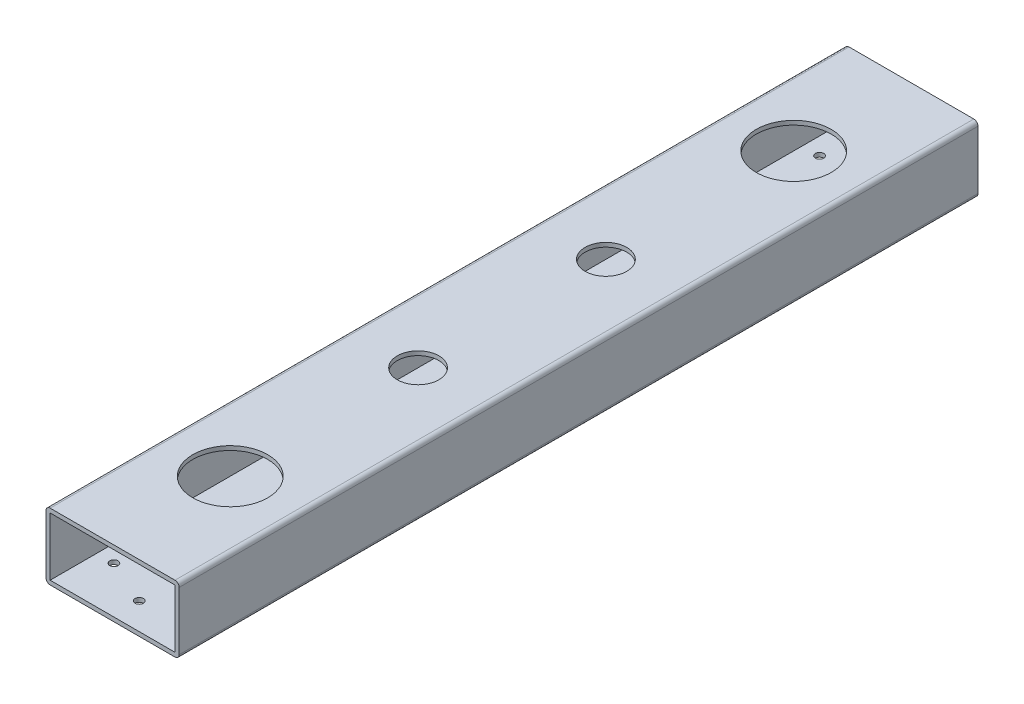
from build123d import *

# Parameters (mm, degrees)
SKETCH1_W                      = 47.625
SKETCH1_H                      = 22.225
BOSS_EXTRUDE1_DEPTH            = 304.8
CUT_EXTRUDE1_REACH             = 27.4
SKETCH2_R                      = 14.2875
CUT_EXTRUDE1_DIRECTION_2_DEPTH = 1
CUT_EXTRUDE2_REACH             = 27.4
SKETCH3_R                      = 12.7
CUT_EXTRUDE2_DIRECTION_2_DEPTH = 1
CUT_EXTRUDE5_REACH             = 27.4
SKETCH6_R                      = 3.3782
CUT_EXTRUDE5_DIRECTION_2_DEPTH = 1
CUT_EXTRUDE6_REACH             = 27.4
SKETCH7_R                      = 7.9375
CUT_EXTRUDE6_DIRECTION_2_DEPTH = 1
CUT_EXTRUDE7_REACH             = 27.4
SKETCH8_R                      = 1.5875
CUT_EXTRUDE7_DIRECTION_2_DEPTH = 1


with BuildPart() as part:
    # Sketch1 → Boss-Extrude1 (new body)
    with BuildSketch(Plane.XY):
        with BuildLine():
            Line((-23.8125, -12.7), (23.8125, -12.7))
            ThreePointArc((23.8125, -12.7), (24.935032015, -12.235032015), (25.4, -11.1125))
            Line((25.4, -11.1125), (25.4, 11.1125))
            ThreePointArc((25.4, 11.1125), (24.935032015, 12.235032015), (23.8125, 12.7))
            Line((23.8125, 12.7), (-23.8125, 12.7))
            ThreePointArc((-23.8125, 12.7), (-24.935032015, 12.235032015), (-25.4, 11.1125))
            Line((-25.4, 11.1125), (-25.4, -11.1125))
            ThreePointArc((-25.4, -11.1125), (-24.935032015, -12.235032015), (-23.8125, -12.7))
        make_face()
        Rectangle(SKETCH1_W, SKETCH1_H, mode=Mode.SUBTRACT)
    extrude(amount=BOSS_EXTRUDE1_DEPTH)

    # Sketch2 → Cut-Extrude1 (cut, up to next)
    with BuildSketch(Plane(origin=(0, 12.7, 0), x_dir=(1, 0, 0), z_dir=(0, 1, 0)), mode=Mode.PRIVATE) as cut_extrude1_sk1:
        with Locations((0, -259.9)):
            Circle(SKETCH2_R)
    cut_extrude1_tool1 = extrude(cut_extrude1_sk1.sketch, amount=-CUT_EXTRUDE1_REACH, mode=Mode.PRIVATE) & part.part
    add(cut_extrude1_tool1.solids().sort_by_distance((0, 12.7, 259.9))[0], mode=Mode.SUBTRACT)
    # Sketch2 → Cut-Extrude1 (cut, up to next)
    with BuildSketch(Plane(origin=(0, 12.7, 0), x_dir=(1, 0, 0), z_dir=(0, 1, 0)), mode=Mode.PRIVATE) as cut_extrude1_sk2:
        with Locations((0, -44.9)):
            Circle(SKETCH2_R)
    cut_extrude1_tool2 = extrude(cut_extrude1_sk2.sketch, amount=-CUT_EXTRUDE1_REACH, mode=Mode.PRIVATE) & part.part
    add(cut_extrude1_tool2.solids().sort_by_distance((0, 12.7, 44.9))[0], mode=Mode.SUBTRACT)

    # Sketch2 → Cut-Extrude1 direction 2 (cut)
    with BuildSketch(Plane(origin=(0, 12.7, 0), x_dir=(1, 0, 0), z_dir=(0, 1, 0))):
        with Locations((0, -259.9)):
            Circle(SKETCH2_R)
        with Locations((0, -44.9)):
            Circle(SKETCH2_R)
    extrude(amount=CUT_EXTRUDE1_DIRECTION_2_DEPTH, mode=Mode.SUBTRACT)

    # Sketch3 → Cut-Extrude2 (cut, up to next)
    with BuildSketch(Plane.XZ.offset(12.7), mode=Mode.PRIVATE) as cut_extrude2_sk1:
        with Locations((0, 44.9)):
            Circle(SKETCH3_R)
    cut_extrude2_tool1 = extrude(cut_extrude2_sk1.sketch, amount=-CUT_EXTRUDE2_REACH, mode=Mode.PRIVATE) & part.part
    add(cut_extrude2_tool1.solids().sort_by_distance((0, -12.7, 44.9))[0], mode=Mode.SUBTRACT)
    # Sketch3 → Cut-Extrude2 (cut, up to next)
    with BuildSketch(Plane.XZ.offset(12.7), mode=Mode.PRIVATE) as cut_extrude2_sk2:
        with Locations((0, 259.9)):
            Circle(SKETCH3_R)
    cut_extrude2_tool2 = extrude(cut_extrude2_sk2.sketch, amount=-CUT_EXTRUDE2_REACH, mode=Mode.PRIVATE) & part.part
    add(cut_extrude2_tool2.solids().sort_by_distance((0, -12.7, 259.9))[0], mode=Mode.SUBTRACT)

    # Sketch3 → Cut-Extrude2 direction 2 (cut)
    with BuildSketch(Plane.XZ.offset(12.7)):
        with Locations((0, 44.9)):
            Circle(SKETCH3_R)
        with Locations((0, 259.9)):
            Circle(SKETCH3_R)
    extrude(amount=CUT_EXTRUDE2_DIRECTION_2_DEPTH, mode=Mode.SUBTRACT)

    # Sketch6 → Cut-Extrude5 (cut, up to next)
    with BuildSketch(Plane.XZ.offset(12.7), mode=Mode.PRIVATE) as cut_extrude5_sk1:
        with Locations((0, 116.566667182)):
            Circle(SKETCH6_R)
    cut_extrude5_tool1 = extrude(cut_extrude5_sk1.sketch, amount=-CUT_EXTRUDE5_REACH, mode=Mode.PRIVATE) & part.part
    add(cut_extrude5_tool1.solids().sort_by_distance((0, -12.7, 116.566667))[0], mode=Mode.SUBTRACT)
    # Sketch6 → Cut-Extrude5 (cut, up to next)
    with BuildSketch(Plane.XZ.offset(12.7), mode=Mode.PRIVATE) as cut_extrude5_sk2:
        with Locations((0, 188.233332818)):
            Circle(SKETCH6_R)
    cut_extrude5_tool2 = extrude(cut_extrude5_sk2.sketch, amount=-CUT_EXTRUDE5_REACH, mode=Mode.PRIVATE) & part.part
    add(cut_extrude5_tool2.solids().sort_by_distance((0, -12.7, 188.233333))[0], mode=Mode.SUBTRACT)

    # Sketch6 → Cut-Extrude5 direction 2 (cut)
    with BuildSketch(Plane.XZ.offset(12.7)):
        with Locations((0, 116.566667182)):
            Circle(SKETCH6_R)
        with Locations((0, 188.233332818)):
            Circle(SKETCH6_R)
    extrude(amount=CUT_EXTRUDE5_DIRECTION_2_DEPTH, mode=Mode.SUBTRACT)

    # Sketch7 → Cut-Extrude6 (cut, up to next)
    with BuildSketch(Plane(origin=(0, 12.7, 0), x_dir=(1, 0, 0), z_dir=(0, 1, 0)), mode=Mode.PRIVATE) as cut_extrude6_sk1:
        with Locations((0, -116.566667182)):
            Circle(SKETCH7_R)
    cut_extrude6_tool1 = extrude(cut_extrude6_sk1.sketch, amount=-CUT_EXTRUDE6_REACH, mode=Mode.PRIVATE) & part.part
    add(cut_extrude6_tool1.solids().sort_by_distance((0, 12.7, 116.566667))[0], mode=Mode.SUBTRACT)
    # Sketch7 → Cut-Extrude6 (cut, up to next)
    with BuildSketch(Plane(origin=(0, 12.7, 0), x_dir=(1, 0, 0), z_dir=(0, 1, 0)), mode=Mode.PRIVATE) as cut_extrude6_sk2:
        with Locations((0, -188.233332818)):
            Circle(SKETCH7_R)
    cut_extrude6_tool2 = extrude(cut_extrude6_sk2.sketch, amount=-CUT_EXTRUDE6_REACH, mode=Mode.PRIVATE) & part.part
    add(cut_extrude6_tool2.solids().sort_by_distance((0, 12.7, 188.233333))[0], mode=Mode.SUBTRACT)

    # Sketch7 → Cut-Extrude6 direction 2 (cut)
    with BuildSketch(Plane(origin=(0, 12.7, 0), x_dir=(1, 0, 0), z_dir=(0, 1, 0))):
        with Locations((0, -116.566667182)):
            Circle(SKETCH7_R)
        with Locations((0, -188.233332818)):
            Circle(SKETCH7_R)
    extrude(amount=CUT_EXTRUDE6_DIRECTION_2_DEPTH, mode=Mode.SUBTRACT)

    # Sketch8 → Cut-Extrude7 (cut, up to next)
    with BuildSketch(Plane.XZ.offset(12.7), mode=Mode.PRIVATE) as cut_extrude7_sk1:
        with Locations((17.272, 287.02)):
            Circle(SKETCH8_R)
    cut_extrude7_tool1 = extrude(cut_extrude7_sk1.sketch, amount=-CUT_EXTRUDE7_REACH, mode=Mode.PRIVATE) & part.part
    add(cut_extrude7_tool1.solids().sort_by_distance((17.272, -12.7, 287.02))[0], mode=Mode.SUBTRACT)
    # Sketch8 → Cut-Extrude7 (cut, up to next)
    with BuildSketch(Plane.XZ.offset(12.7), mode=Mode.PRIVATE) as cut_extrude7_sk2:
        with Locations((0, 294.64)):
            Circle(SKETCH8_R)
    cut_extrude7_tool2 = extrude(cut_extrude7_sk2.sketch, amount=-CUT_EXTRUDE7_REACH, mode=Mode.PRIVATE) & part.part
    add(cut_extrude7_tool2.solids().sort_by_distance((0, -12.7, 294.64))[0], mode=Mode.SUBTRACT)
    # Sketch8 → Cut-Extrude7 (cut, up to next)
    with BuildSketch(Plane.XZ.offset(12.7), mode=Mode.PRIVATE) as cut_extrude7_sk3:
        with Locations((-17.272, 287.02)):
            Circle(SKETCH8_R)
    cut_extrude7_tool3 = extrude(cut_extrude7_sk3.sketch, amount=-CUT_EXTRUDE7_REACH, mode=Mode.PRIVATE) & part.part
    add(cut_extrude7_tool3.solids().sort_by_distance((-17.272, -12.7, 287.02))[0], mode=Mode.SUBTRACT)
    # Sketch8 → Cut-Extrude7 (cut, up to next)
    with BuildSketch(Plane.XZ.offset(12.7), mode=Mode.PRIVATE) as cut_extrude7_sk4:
        with Locations((-17.272, 17.78)):
            Circle(SKETCH8_R)
    cut_extrude7_tool4 = extrude(cut_extrude7_sk4.sketch, amount=-CUT_EXTRUDE7_REACH, mode=Mode.PRIVATE) & part.part
    add(cut_extrude7_tool4.solids().sort_by_distance((-17.272, -12.7, 17.78))[0], mode=Mode.SUBTRACT)
    # Sketch8 → Cut-Extrude7 (cut, up to next)
    with BuildSketch(Plane.XZ.offset(12.7), mode=Mode.PRIVATE) as cut_extrude7_sk5:
        with Locations((0, 10.16)):
            Circle(SKETCH8_R)
    cut_extrude7_tool5 = extrude(cut_extrude7_sk5.sketch, amount=-CUT_EXTRUDE7_REACH, mode=Mode.PRIVATE) & part.part
    add(cut_extrude7_tool5.solids().sort_by_distance((0, -12.7, 10.16))[0], mode=Mode.SUBTRACT)
    # Sketch8 → Cut-Extrude7 (cut, up to next)
    with BuildSketch(Plane.XZ.offset(12.7), mode=Mode.PRIVATE) as cut_extrude7_sk6:
        with Locations((17.272, 17.78)):
            Circle(SKETCH8_R)
    cut_extrude7_tool6 = extrude(cut_extrude7_sk6.sketch, amount=-CUT_EXTRUDE7_REACH, mode=Mode.PRIVATE) & part.part
    add(cut_extrude7_tool6.solids().sort_by_distance((17.272, -12.7, 17.78))[0], mode=Mode.SUBTRACT)

    # Sketch8 → Cut-Extrude7 direction 2 (cut)
    with BuildSketch(Plane.XZ.offset(12.7)):
        with Locations((17.272, 287.02)):
            Circle(SKETCH8_R)
        with Locations((0, 294.64)):
            Circle(SKETCH8_R)
        with Locations((-17.272, 287.02)):
            Circle(SKETCH8_R)
        with Locations((-17.272, 17.78)):
            Circle(SKETCH8_R)
        with Locations((0, 10.16)):
            Circle(SKETCH8_R)
        with Locations((17.272, 17.78)):
            Circle(SKETCH8_R)
    extrude(amount=CUT_EXTRUDE7_DIRECTION_2_DEPTH, mode=Mode.SUBTRACT)


solid = part.part
